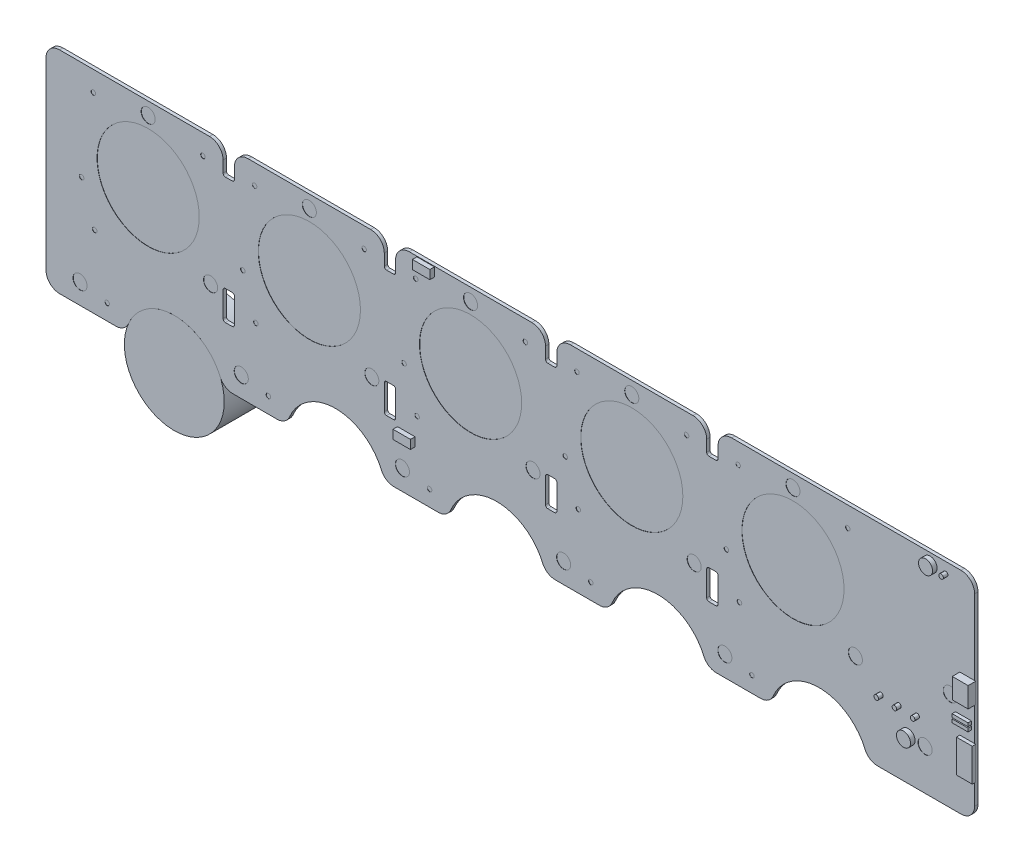
from build123d import *

# Parameters (mm, degrees)
ESQUISSE1_W                                = 409
ESQUISSE1_H                                = 93
PCB_RECTANGULAIRE_DEPTH                    = 1.5
ESQUISSE1_3_R                              = 22.5
POSITION_TROU_DEPTH                        = 0.1
PASSAGE_APPUI_FLANC_ET_PASSAGE_JETON_DEPTH = 230.970106753
R_P_TITION_LIN_AIRE1_COUNT                 = 4
R_P_TITION_LIN_AIRE1_PITCH                 = 71
ESQUISSE2_R                                = 1
ESQUISSE2_R_2                              = 3.1
POSITION_CAPTEUR_LED_DEPTH                 = 0.1
ESQUISSE4_R                                = 22
ECHAPPEMENT_DEPTH                          = 230.970106753
R_P_TITION_LIN_AIRE3_COUNT                 = 5
R_P_TITION_LIN_AIRE3_PITCH                 = 71
CONG_1_R                                   = 6
ESQUISSE5_R                                = 1
ESQUISSE5_R_2                              = 3.1
ESQUISSE5_W                                = 7.707134
ESQUISSE5_H                                = 3.889125
BOUTON_ET_IR_DEPTH                         = 2
COTE_DROIT_START                           = 0.5
ESQUISSE6_W                                = 3.335002
ESQUISSE6_H                                = 8.94
ESQUISSE6_W_2                              = 1.535001209
ESQUISSE6_H_2                              = 14.45
ESQUISSE6_W_3                              = 1.5
ESQUISSE6_H_3                              = 1.5
COTE_DROIT_DEPTH                           = 7
ESQUISSE4_2_R                              = 22
DEGAGEMENT_JETON_DEPTH                     = 20


with BuildPart() as part:
    # Esquisse1 → PCB_rectangulaire (new body)
    with BuildSketch(Plane.XY):
        with Locations((17.5, -13.5)):
            Rectangle(ESQUISSE1_W, ESQUISSE1_H)
    extrude(amount=-PCB_RECTANGULAIRE_DEPTH)

    # Esquisse1_3 → position_trou (cut)
    with BuildSketch(Plane.XY):
        with Locations((-142, 0)):
            Circle(ESQUISSE1_3_R)
        with Locations((-71, 0)):
            Circle(ESQUISSE1_3_R)
        Circle(ESQUISSE1_3_R)
        with Locations((71, 0)):
            Circle(ESQUISSE1_3_R)
        with Locations((142, 0)):
            Circle(ESQUISSE1_3_R)
    extrude(amount=-POSITION_TROU_DEPTH, mode=Mode.SUBTRACT)

    # Esquisse3 → passage_appui_flanc et passage jeton (cut, through all)
    with BuildSketch(Plane.XY):
        with BuildLine():
            Line((-109, 33), (-104, 33))
            Line((-104, 33), (-104, 22))
            ThreePointArc((-104, 22), (-104.292893219, 21.292893219), (-105, 21))
            Line((-105, 21), (-108, 21))
            ThreePointArc((-108, 21), (-108.707106781, 21.292893219), (-109, 22))
            Line((-109, 22), (-109, 33))
        make_face()
        with BuildLine():
            Line((-108, -21.5), (-105, -21.5))
            ThreePointArc((-105, -21.5), (-104.292893219, -21.792893219), (-104, -22.5))
            Line((-104, -22.5), (-104, -33.5))
            ThreePointArc((-104, -33.5), (-104.292893219, -34.207106781), (-105, -34.5))
            Line((-105, -34.5), (-108, -34.5))
            ThreePointArc((-108, -34.5), (-108.707106781, -34.207106781), (-109, -33.5))
            Line((-109, -33.5), (-109, -22.5))
            ThreePointArc((-109, -22.5), (-108.707106781, -21.792893219), (-108, -21.5))
        make_face()
    passage_appui_flanc_et_passage_jeton = extrude(amount=-PASSAGE_APPUI_FLANC_ET_PASSAGE_JETON_DEPTH, mode=Mode.SUBTRACT)

    # Répétition linéaire1: passage_appui_flanc et passage jeton ×4
    with Locations(*[(i * R_P_TITION_LIN_AIRE1_PITCH, 0, 0) for i in range(1, R_P_TITION_LIN_AIRE1_COUNT)]):
        add(passage_appui_flanc_et_passage_jeton, mode=Mode.SUBTRACT)

    # Esquisse2 → position_capteur-LED (cut)
    with BuildSketch(Plane.XY):
        with Locations((-171.292893219, -10.707106781)):
            Circle(ESQUISSE2_R)
        with Locations((-165.54936099, -28)):
            Circle(ESQUISSE2_R)
        with Locations((-160.056223834, -53.056223834)):
            Circle(ESQUISSE2_R)
        with Locations((-166.137557081, 24.137557081)):
            Circle(ESQUISSE2_R)
        with Locations((-117.862442919, 24.137557081)):
            Circle(ESQUISSE2_R)
        with Locations((-172, -51)):
            Circle(ESQUISSE2_R_2)
        with Locations((-114.5, -23)):
            Circle(ESQUISSE2_R_2)
        with Locations((-142, 27.5)):
            Circle(ESQUISSE2_R_2)
        with Locations((211.29236, -16.587496544)):
            Circle(ESQUISSE2_R_2)
        with Locations((200.19236, -42.087496544)):
            Circle(ESQUISSE2_R_2)
    position_capteur_led = extrude(amount=-POSITION_CAPTEUR_LED_DEPTH, mode=Mode.SUBTRACT)

    # Esquisse4 → echappement (cut, through all)
    with BuildSketch(Plane.XY):
        with Locations((-130.5, -65)):
            Circle(ESQUISSE4_R)
    echappement = extrude(amount=-ECHAPPEMENT_DEPTH, mode=Mode.SUBTRACT)

    # Répétition linéaire3: position_capteur-LED, echappement ×5
    with Locations(*[(i * R_P_TITION_LIN_AIRE3_PITCH, 0, 0) for i in range(1, R_P_TITION_LIN_AIRE3_COUNT)]):
        add(position_capteur_led, mode=Mode.SUBTRACT)
        add(echappement, mode=Mode.SUBTRACT)

    # Congé1
    cong_1_edges = [part.edges().sort_by_distance(p)[0] for p in [
        (-187, -60, -0.75),
        (-187, 33, -0.75),
        (-109, 33, -0.75),
        (-104, 33, -0.75),
        (-38, 33, -0.75),
        (-33, 33, -0.75),
        (33, 33, -0.75),
        (38, 33, -0.75),
        (104, 33, -0.75),
        (109, 33, -0.75),
        (222, 33, -0.75),
        (222, -60, -0.75),
        (-109.075714714, -60, -0.75),
        (-151.924285286, -60, -0.75),
        (174.924285286, -60, -0.75),
        (132.075714714, -60, -0.75),
        (103.924285286, -60, -0.75),
        (61.075714714, -60, -0.75),
        (32.924285286, -60, -0.75),
        (-9.924285286, -60, -0.75),
        (-38.075714714, -60, -0.75),
        (-80.924285286, -60, -0.75),
    ]]
    fillet(cong_1_edges, radius=CONG_1_R)

    # Esquisse5 → bouton et IR (add)
    with BuildSketch(Plane.XY):
        with Locations((180.69236, -32.187496544)):
            Circle(ESQUISSE5_R)
        with Locations((188.69236, -32.187496544)):
            Circle(ESQUISSE5_R)
        with Locations((196.69236, -32.187496544)):
            Circle(ESQUISSE5_R)
        with Locations((209.239488, 28.264213456)):
            Circle(ESQUISSE5_R)
        with Locations((192.69236, -42.087496544)):
            Circle(ESQUISSE5_R_2)
        with Locations((202.39236, 28.512503456)):
            Circle(ESQUISSE5_R_2)
        with Locations((-19.775015, 30.807550956)):
            Rectangle(ESQUISSE5_W, ESQUISSE5_H)
        with Locations((-28.322143, -38.242450044)):
            Rectangle(ESQUISSE5_W, ESQUISSE5_H)
    extrude(amount=BOUTON_ET_IR_DEPTH)

    # Esquisse6 → cote_droit (add)
    with BuildSketch(Plane(origin=(222, 0, 0), x_dir=(0, 0, -1), z_dir=(1, 0, 0)).offset(COTE_DROIT_START)):
        with Locations((-1.667501, -10.537494544)):
            Rectangle(ESQUISSE6_W, ESQUISSE6_H)
        with Locations((-0.767500605, -37.337443744)):
            Rectangle(ESQUISSE6_W_2, ESQUISSE6_H_2)
        with Locations((-2.65, -22.987496544)):
            Rectangle(ESQUISSE6_W_3, ESQUISSE6_H_3)
        with Locations((-2.65, -20.987496544)):
            Rectangle(ESQUISSE6_W_3, ESQUISSE6_H_3)
    extrude(amount=-COTE_DROIT_DEPTH)


with BuildPart() as cote_droit_piece_1:
    # of the separate pieces the step leaves, piece 1, a body of its own (cote_droit_pieces)
    add(part.part.solids().sort_by_distance((-181, 33, 0))[0])


with BuildPart() as cote_droit_piece_2:
    # of the separate pieces the step leaves, piece 2, a body of its own (cote_droit_pieces)
    add(part.part.solids().sort_by_distance((222.5, -22.237496544, 3.4))[0])


with BuildPart() as cote_droit_piece_3:
    # of the separate pieces the step leaves, piece 3, a body of its own (cote_droit_pieces)
    add(part.part.solids().sort_by_distance((222.5, -20.237496544, 3.4))[0])


with BuildPart() as body_4:
    # Esquisse4_2 → degagement_jeton (new body)
    with BuildSketch(Plane.XY):
        with Locations((-130.5, -65)):
            Circle(ESQUISSE4_2_R)
    extrude(amount=-DEGAGEMENT_JETON_DEPTH)


solid = Compound([cote_droit_piece_1.part, cote_droit_piece_2.part, cote_droit_piece_3.part, body_4.part])
